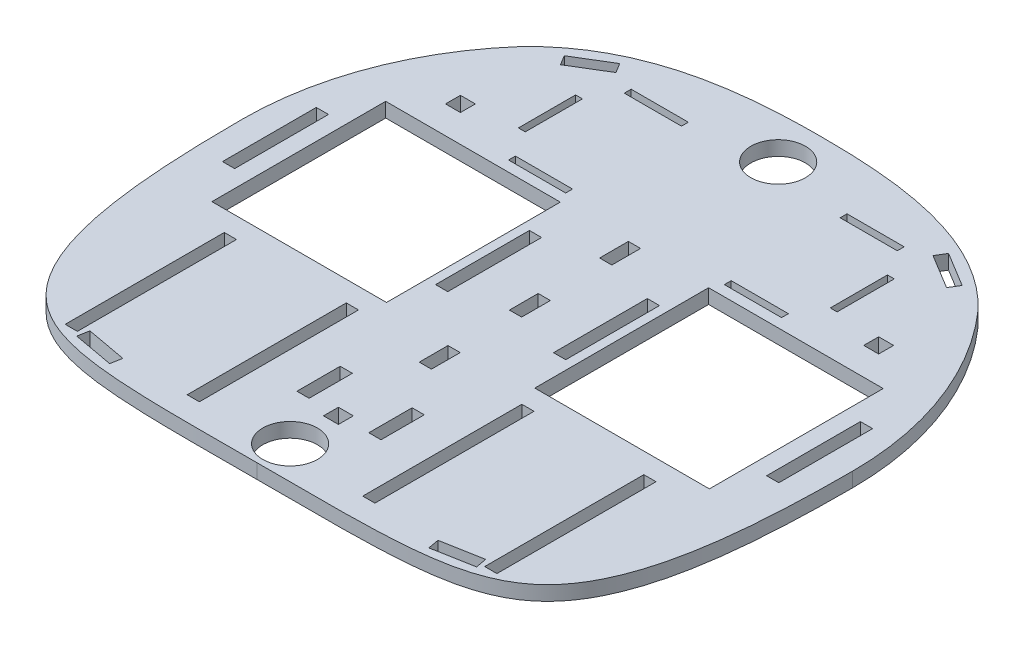
from build123d import *

# Parameters (mm, degrees)
BASE_DEPTH            = 6.35
SKETCH6_W             = 76.3515
SKETCH6_H             = 76
SKETCH6_W_2           = 5.334
SKETCH6_H_2           = 41.021
WHEELSHAFTCUT_DEPTH   = 7.3500001
SKETCH8_W             = 5.334
SKETCH8_H             = 69.573
SKETCH8_H_2           = 18.923
MOTORCUT_DEPTH        = 7.3500001
SKETCH10_W            = 25
SKETCH10_H            = 3
SKETCH10_W_2          = 3
SKETCH10_H_2          = 25
VELCROCUT_DEPTH       = 7.3500001
SKETCH11_W            = 6.5278
SKETCH11_H            = 6.5278
SCREWCUT_DEPTH        = 7.3500001
SKETCH13_W            = 5.334
SKETCH13_H            = 12.573
SUPPORTSTRUTCUT_DEPTH = 7.3500001
EMPTYSPACETRIM_DEPTH  = 7.3500001
TAPESENSORCUT_DEPTH   = 7.3500001
SKETCH17_R            = 11.938
CASTERCUT_DEPTH       = 7.3500001


with BuildPart() as part:
    # Sketch1 → Base (new body)
    with BuildSketch(Plane(origin=(0, 0, 0), x_dir=(1, 0, 0), z_dir=(0, 1, 0))):
        with BuildLine():
            ThreePointArc((133.35, 0), (0, 133.35), (-133.35, 0))
            add(Edge.make_bspline(
                [(-133.35, 0), (-133.35, -51.197979728), (-123.803376308, -129.805052089), (-58.427993604, -127), (0, -127)],
                knots=[0, 0, 0, 0, 0.502616309, 1, 1, 1, 1], degree=3))
            add(Edge.make_bspline(
                [(133.35, 0), (133.35, -51.197979728), (123.803376308, -129.805052089), (58.427993604, -127), (0, -127)],
                knots=[0, 0, 0, 0, 0.502616309, 1, 1, 1, 1], degree=3))
        make_face()
    extrude(amount=BASE_DEPTH)

    # Sketch6 → WheelShaftCut (cut, through all)
    with BuildSketch(Plane(origin=(0, 6.35, 0), x_dir=(1, 0, 0), z_dir=(0, 1, 0))):
        with Locations((-70.592348141, 0)):
            Rectangle(SKETCH6_W, SKETCH6_H)
        with Locations((-118.959848141, 0)):
            Rectangle(SKETCH6_W_2, SKETCH6_H_2)
        with Locations((-25.780848141, 0)):
            Rectangle(SKETCH6_W_2, SKETCH6_H_2)
        with Locations((25.780848141, 0)):
            Rectangle(SKETCH6_W_2, SKETCH6_H_2)
        with Locations((118.959848141, 0)):
            Rectangle(SKETCH6_W_2, SKETCH6_H_2)
        with Locations((70.592348141, 0)):
            Rectangle(SKETCH6_W, SKETCH6_H)
    extrude(amount=-WHEELSHAFTCUT_DEPTH, mode=Mode.SUBTRACT)

    # Sketch8 → MotorCut (cut, through all)
    with BuildSketch(Plane(origin=(0, 6.35, 0), x_dir=(1, 0, 0), z_dir=(0, 1, 0))):
        with Locations((-38.378348141, -81.74)):
            Rectangle(SKETCH8_W, SKETCH8_H)
        with Locations((-91.718348141, -81.74)):
            Rectangle(SKETCH8_W, SKETCH8_H)
        with Locations((15.718348141, -81.74)):
            Rectangle(SKETCH8_W, SKETCH8_H_2)
        with Locations((91.718348141, -81.74)):
            Rectangle(SKETCH8_W, SKETCH8_H)
        with Locations((38.378348141, -81.74)):
            Rectangle(SKETCH8_W, SKETCH8_H)
        with Locations((-15.718348141, -81.74)):
            Rectangle(SKETCH8_W, SKETCH8_H_2)
    extrude(amount=-MOTORCUT_DEPTH, mode=Mode.SUBTRACT)

    # Sketch10 → VelcroCut (cut, through all)
    with BuildSketch(Plane(origin=(0, 6.35, 0), x_dir=(1, 0, 0), z_dir=(0, 1, 0))):
        with Locations((-47.19, 44.12)):
            Rectangle(SKETCH10_W, SKETCH10_H)
        with Locations((-47.19, 94.745)):
            Rectangle(SKETCH10_W, SKETCH10_H)
        with Locations((-68.175, 69.4325)):
            Rectangle(SKETCH10_W_2, SKETCH10_H_2)
        with Locations((68.175, 69.4325)):
            Rectangle(SKETCH10_W_2, SKETCH10_H_2)
        with Locations((47.19, 94.745)):
            Rectangle(SKETCH10_W, SKETCH10_H)
        with Locations((47.19, 44.12)):
            Rectangle(SKETCH10_W, SKETCH10_H)
    extrude(amount=-VELCROCUT_DEPTH, mode=Mode.SUBTRACT)

    # Sketch11 → ScrewCut (cut, through all)
    with BuildSketch(Plane(origin=(0, 6.35, 0), x_dir=(1, 0, 0), z_dir=(0, 1, 0))):
        with Locations((-91.44, 53.34)):
            Rectangle(SKETCH11_W, SKETCH11_H)
        with Locations((91.44, 53.34)):
            Rectangle(SKETCH11_W, SKETCH11_H)
        with Locations((0, -91.44)):
            Rectangle(SKETCH11_W, SKETCH11_H)
    extrude(amount=-SCREWCUT_DEPTH, mode=Mode.SUBTRACT)

    # Sketch13 → SupportStrutCut (cut, through all)
    with BuildSketch(Plane(origin=(0, 6.35, 0), x_dir=(1, 0, 0), z_dir=(0, 1, 0))):
        with Locations((0, 31.7135)):
            Rectangle(SKETCH13_W, SKETCH13_H)
        with Locations((0, -7.72)):
            Rectangle(SKETCH13_W, SKETCH13_H)
        with Locations((0, -47.1535)):
            Rectangle(SKETCH13_W, SKETCH13_H)
    extrude(amount=-SUPPORTSTRUTCUT_DEPTH, mode=Mode.SUBTRACT)

    # Sketch16 → EmptySpaceTrim (cut, through all)
    with BuildSketch(Plane(origin=(0, 6.35, 0), x_dir=(1, 0, 0), z_dir=(0, 1, 0))):
        with BuildLine():
            Line((-100.033122546, 133.35), (-100.033122546, 88.179345052))
            add(Edge.make_bspline(
                [(-100.033122546, 88.179345052), (-73.919529929, 115.91021885), (-34.972901221, 119.822808394), (0, 119.822808394)],
                knots=[0, 0, 0, 0, 1, 1, 1, 1], degree=3))
            add(Edge.make_bspline(
                [(100.033122546, 88.179345052), (73.919529929, 115.91021885), (34.972901221, 119.822808394), (0, 119.822808394)],
                knots=[0, 0, 0, 0, 1, 1, 1, 1], degree=3))
            Line((100.033122546, 88.179345052), (100.033122546, 133.35))
            Line((100.033122546, 133.35), (-100.033122546, 133.35))
        make_face()
    extrude(amount=-EMPTYSPACETRIM_DEPTH, mode=Mode.SUBTRACT)

    # Sketch15 → TapeSensorCut (cut, through all)
    with BuildSketch(Plane(origin=(0, 6.35, 0), x_dir=(1, 0, 0), z_dir=(0, 1, 0))):
        Polygon((-87.418704088, -118.459321106), (-69.765704088, -121.679864084), (-68.876770565, -116.807287128), (-86.529770565, -113.58674415), align=None)
        Polygon((-84.406611309, 90.060423031), (-69.317948313, 99.223427887), (-71.888863344, 103.456937649), (-86.97752634, 94.293932793), align=None)
        Polygon((86.97752634, 94.293932793), (71.888863344, 103.456937649), (69.317948313, 99.223427887), (84.406611309, 90.060423031), align=None)
        Polygon((86.529770565, -113.58674415), (68.876770565, -116.807287128), (69.765704088, -121.679864084), (87.418704088, -118.459321106), align=None)
    extrude(amount=-TAPESENSORCUT_DEPTH, mode=Mode.SUBTRACT)

    # Sketch17 → CasterCut (cut, through all)
    with BuildSketch(Plane(origin=(0, 6.35, 0), x_dir=(1, 0, 0), z_dir=(0, 1, 0))):
        with Locations((0, 100.834589665)):
            Circle(SKETCH17_R)
        with Locations((0, -112.562458365)):
            Circle(SKETCH17_R)
    extrude(amount=-CASTERCUT_DEPTH, mode=Mode.SUBTRACT)


solid = part.part
